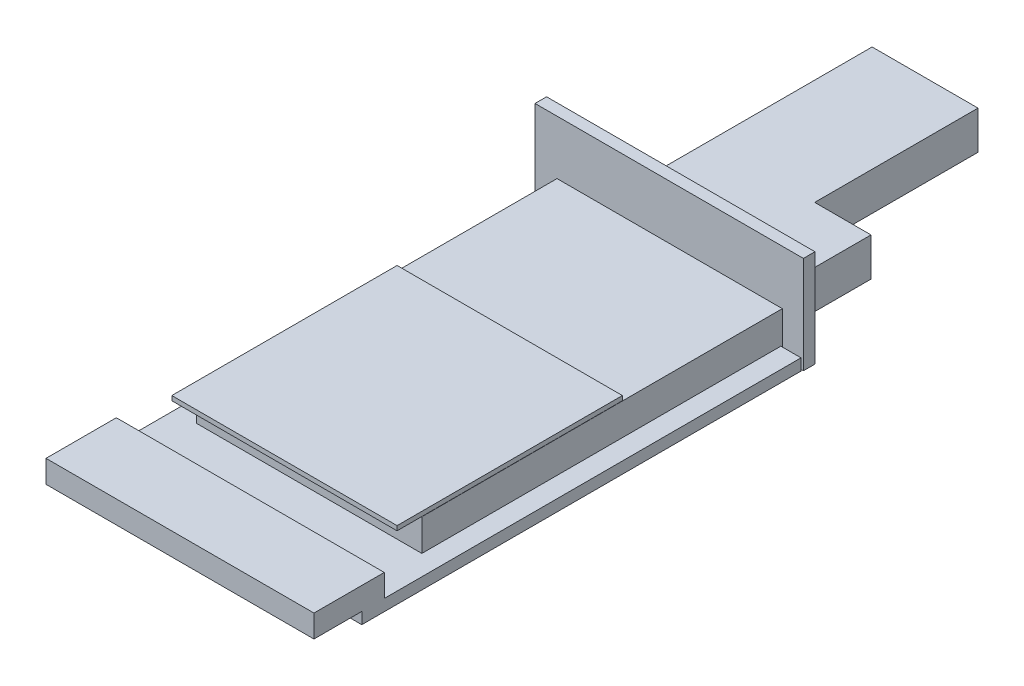
from build123d import *

# Parameters (mm, degrees)
SKETCH3_W            = 151.302132641
SKETCH3_H            = 6.5151
BOSS_EXTRUDE1_DEPTH  = 54.864
SKETCH3_13_W         = 151.052545821
SKETCH3_13_H         = 247.635016114
BOSS_EXTRUDE4_DEPTH  = 6.477
BOSS_EXTRUDE5_START  = 6.477
SKETCH3_14_W         = 151.052545821
SKETCH3_14_H         = 39.648003702
BOSS_EXTRUDE5_DEPTH  = 12.7
SKETCH3_15_W         = 127
SKETCH3_15_H         = 203.2
BOSS_EXTRUDE6_DEPTH  = 24.384
BOSS_EXTRUDE7_START  = 24.511
SKETCH3_16_W         = 127
SKETCH3_16_H         = 127
BOSS_EXTRUDE7_DEPTH  = 2.54
BOSS_EXTRUDE12_START = 6.477
SKETCH3_22_W         = 31.75
SKETCH3_22_H         = 50.8
BOSS_EXTRUDE12_DEPTH = 21.59
BOSS_EXTRUDE13_START = 6.477
SKETCH3_23_W         = 59.69
SKETCH3_23_H         = 142.875
BOSS_EXTRUDE13_DEPTH = 21.59


with BuildPart() as part:
    # Sketch3 → Boss-Extrude1 (new body)
    with BuildSketch(Plane(origin=(0, 0, 0), x_dir=(1, 0, 0), z_dir=(0, 1, 0))):
        with Locations((26.853160792, -93.15368855)):
            Rectangle(SKETCH3_W, SKETCH3_H)
    extrude(amount=BOSS_EXTRUDE1_DEPTH)



with BuildPart() as body_2:
    # Sketch3_13 → Boss-Extrude4 (new body)
    with BuildSketch(Plane(origin=(0, 0, 0), x_dir=(1, 0, 0), z_dir=(0, 1, 0))):
        with Locations((26.460014629, -221.051383358)):
            Rectangle(SKETCH3_13_W, SKETCH3_13_H)
    extrude(amount=BOSS_EXTRUDE4_DEPTH)

    # Sketch3_14 → Boss-Extrude5 (add)
    with BuildSketch(Plane(origin=(0, 0, 0), x_dir=(1, 0, 0), z_dir=(0, 1, 0)).offset(BOSS_EXTRUDE5_START)):
        with Locations((26.460014629, -351.992893266)):
            Rectangle(SKETCH3_14_W, SKETCH3_14_H)
    extrude(amount=BOSS_EXTRUDE5_DEPTH)


with BuildPart() as part_1:
    add(part.part)

    add(body_2.part)  # Boss-Extrude6 merges body 2
    # Sketch3_15 → Boss-Extrude6 (add)
    with BuildSketch(Plane(origin=(0, 0, 0), x_dir=(1, 0, 0), z_dir=(0, 1, 0))):
        with Locations((27.107070751, -198.01123855)):
            Rectangle(SKETCH3_15_W, SKETCH3_15_H)
    extrude(amount=BOSS_EXTRUDE6_DEPTH)

    # Sketch3_22 → Boss-Extrude12 (add)
    with BuildSketch(Plane(origin=(0, 0, 0), x_dir=(1, 0, 0), z_dir=(0, 1, 0)).offset(BOSS_EXTRUDE12_START)):
        with Locations((67.407094471, -64.49613855)):
            Rectangle(SKETCH3_22_W, SKETCH3_22_H)
    extrude(amount=BOSS_EXTRUDE12_DEPTH)

    # Sketch3_23 → Boss-Extrude13 (add)
    with BuildSketch(Plane(origin=(0, 0, 0), x_dir=(1, 0, 0), z_dir=(0, 1, 0)).offset(BOSS_EXTRUDE13_START)):
        with Locations((21.687094471, -18.45863855)):
            Rectangle(SKETCH3_23_W, SKETCH3_23_H)
    extrude(amount=BOSS_EXTRUDE13_DEPTH)


with BuildPart() as body_2_2:
    # Sketch3_16 → Boss-Extrude7 (new body)
    with BuildSketch(Plane(origin=(0, 0, 0), x_dir=(1, 0, 0), z_dir=(0, 1, 0)).offset(BOSS_EXTRUDE7_START)):
        with Locations((27.107070751, -250.08123855)):
            Rectangle(SKETCH3_16_W, SKETCH3_16_H)
    extrude(amount=BOSS_EXTRUDE7_DEPTH)


solid = Compound([part_1.part, body_2_2.part])
